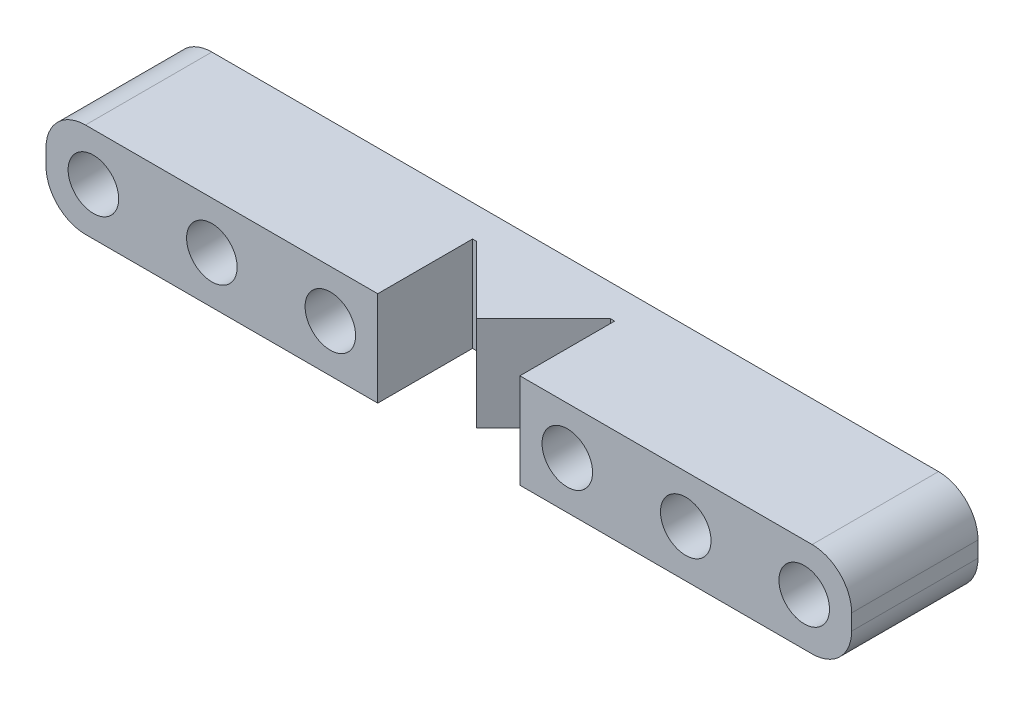
from build123d import *

# Parameters (mm, degrees)
SKETCH1_R           = 1.6
BOSS_EXTRUDE1_DEPTH = 8
SKETCH2_W           = 9
SKETCH2_H           = 8.199711987
CUT_EXTRUDE1_DEPTH  = 8
BOSS_EXTRUDE2_DEPTH = 6
SKETCH4_R           = 1.6
BOSS_EXTRUDE3_DEPTH = 8


with BuildPart() as part:
    # Sketch1 → Boss-Extrude1 (new body)
    with BuildSketch(Plane.XY):
        with BuildLine():
            Line((-0.5, 3), (15.5, 3))
            ThreePointArc((15.5, 3), (17.267766953, 2.267766953), (18, 0.5))
            Line((18, 0.5), (18, -0.5))
            ThreePointArc((18, -0.5), (17.267766953, -2.267766953), (15.5, -3))
            Line((15.5, -3), (-0.5, -3))
            ThreePointArc((-0.5, -3), (-2.267766953, -2.267766953), (-3, -0.5))
            Line((-3, -0.5), (-3, 0.5))
            ThreePointArc((-3, 0.5), (-2.267766953, 2.267766953), (-0.5, 3))
        make_face()
        Circle(SKETCH1_R, mode=Mode.SUBTRACT)
        with Locations((15, 0)):
            Circle(SKETCH1_R, mode=Mode.SUBTRACT)
    extrude(amount=BOSS_EXTRUDE1_DEPTH)

    # Sketch2 → Cut-Extrude1 (cut)
    with BuildSketch(Plane.XZ.offset(3)):
        with Locations((7.5, 6.099855994)):
            Rectangle(SKETCH2_W, SKETCH2_H)
    extrude(amount=-CUT_EXTRUDE1_DEPTH, mode=Mode.SUBTRACT)

    # Sketch3 → Boss-Extrude2 (add)
    with BuildSketch(Plane.XZ.offset(3)):
        Polygon((3.257359313, 2), (7.5, 6.242640687), (11.742640687, 2), align=None)
    extrude(amount=-BOSS_EXTRUDE2_DEPTH)

    # Sketch4 → Boss-Extrude3 (add)
    with BuildSketch(Plane(origin=(0, 0, 0), x_dir=(-1, 0, 0), z_dir=(0, 0, -1))):
        with BuildLine():
            Line((15.5, 3), (0.5, 3))
            ThreePointArc((0.5, 3), (2.267766953, 2.267766953), (3, 0.5))
            Line((3, 0.5), (3, -0.5))
            ThreePointArc((3, -0.5), (2.267766953, -2.267766953), (0.5, -3))
            Line((0.5, -3), (15.5, -3))
            ThreePointArc((15.5, -3), (17.267766953, -2.267766953), (18, -0.5))
            Line((18, -0.5), (18, 0.5))
            ThreePointArc((18, 0.5), (17.267766953, 2.267766953), (15.5, 3))
        make_face()
        with Locations((7.5, 0)):
            Circle(SKETCH4_R, mode=Mode.SUBTRACT)
        with Locations((15, 0)):
            Circle(SKETCH4_R, mode=Mode.SUBTRACT)
        with BuildLine():
            ThreePointArc((-18, 0.5), (-17.267766953, 2.267766953), (-15.5, 3))
            Line((-15.5, 3), (-30.5, 3))
            ThreePointArc((-30.5, 3), (-32.267766953, 2.267766953), (-33, 0.5))
            Line((-33, 0.5), (-33, -0.5))
            ThreePointArc((-33, -0.5), (-32.267766953, -2.267766953), (-30.5, -3))
            Line((-30.5, -3), (-15.5, -3))
            ThreePointArc((-15.5, -3), (-17.267766953, -2.267766953), (-18, -0.5))
            Line((-18, -0.5), (-18, 0.5))
        make_face()
        with Locations((-30, 0)):
            Circle(SKETCH4_R, mode=Mode.SUBTRACT)
        with Locations((-22.5, 0)):
            Circle(SKETCH4_R, mode=Mode.SUBTRACT)
    extrude(amount=-BOSS_EXTRUDE3_DEPTH)


solid = part.part
